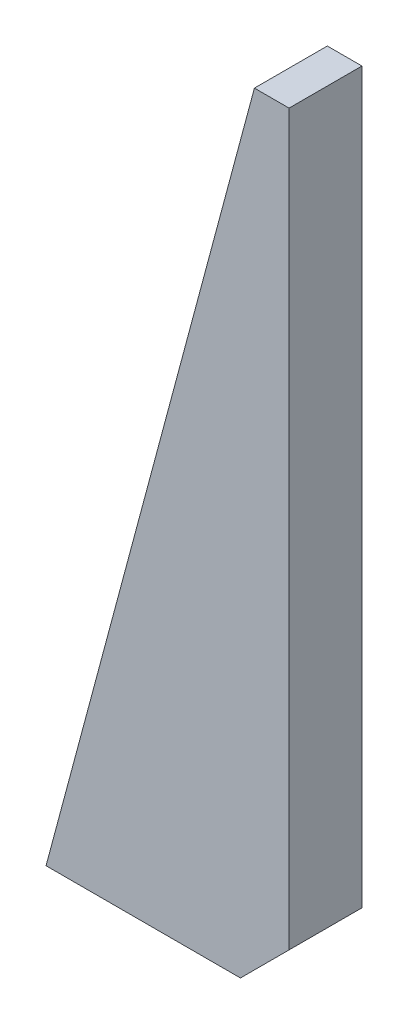
from build123d import *

# Parameters (mm, degrees)
BOSS_EXTRUDE1_DEPTH = 7.5


with BuildPart() as part:
    # Sketch1 → Boss-Extrude1 (new body, symmetric)
    with BuildSketch(Plane.XY):
        Polygon((0, 80), (0, -70), (-10, -80), (-50, -80), (-7.128129211, 80), align=None)
    extrude(amount=BOSS_EXTRUDE1_DEPTH, both=True)


solid = part.part
